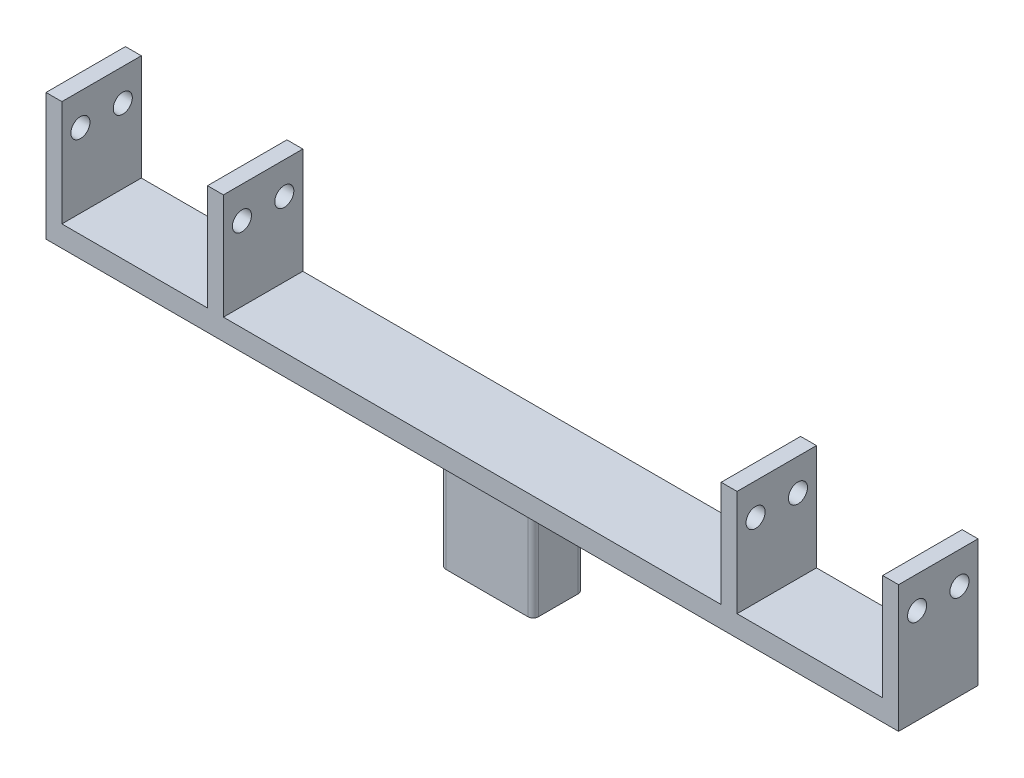
from build123d import *

# Parameters (mm, degrees)
SKETCH1_W               = 161
SKETCH1_H               = 15
BOSS_EXTRUDE1_DEPTH     = 4
SKETCH2_W               = 3
SKETCH2_H               = 15
BOSS_EXTRUDE2_DEPTH     = 20
SKETCH4_R               = 1.8
CUT_EXTRUDE2_DEPTH      = 1
CUT_EXTRUDE2_DEPTH_BACK = 162
BOSS_EXTRUDE3_DEPTH     = 19


with BuildPart() as part:
    # Sketch1 → Boss-Extrude1 (new body)
    with BuildSketch(Plane(origin=(0, 0, 0), x_dir=(1, 0, 0), z_dir=(0, 1, 0))):
        Rectangle(SKETCH1_W, SKETCH1_H)
    extrude(amount=BOSS_EXTRUDE1_DEPTH)

    # Sketch2 → Boss-Extrude2 (add)
    with BuildSketch(Plane(origin=(0, 4, 0), x_dir=(1, 0, 0), z_dir=(0, 1, 0))):
        with Locations((-48.5, 0)):
            Rectangle(SKETCH2_W, SKETCH2_H)
        with Locations((-79, 0)):
            Rectangle(SKETCH2_W, SKETCH2_H)
        with Locations((79, 0)):
            Rectangle(SKETCH2_W, SKETCH2_H)
        with Locations((48.5, 0)):
            Rectangle(SKETCH2_W, SKETCH2_H)
    extrude(amount=BOSS_EXTRUDE2_DEPTH)

    # Sketch4 → Cut-Extrude2 (cut, two sides)
    with BuildSketch(Plane.ZY.offset(80.5)) as cut_extrude2_sk:
        with Locations((4, 18)):
            Circle(SKETCH4_R)
        with Locations((-4, 18)):
            Circle(SKETCH4_R)
    extrude(amount=CUT_EXTRUDE2_DEPTH, mode=Mode.SUBTRACT)
    extrude(cut_extrude2_sk.sketch, amount=-CUT_EXTRUDE2_DEPTH_BACK, mode=Mode.SUBTRACT)

    # Sketch5 → Boss-Extrude3 (add)
    with BuildSketch(Plane.XZ):
        with BuildLine():
            Line((-7.75, -4.75), (7.75, -4.75))
            ThreePointArc((7.75, -4.75), (8.457106781, -4.457106781), (8.75, -3.75))
            Line((8.75, -3.75), (8.75, 3.75))
            ThreePointArc((8.75, 3.75), (8.457106781, 4.457106781), (7.75, 4.75))
            Line((7.75, 4.75), (-7.75, 4.75))
            ThreePointArc((-7.75, 4.75), (-8.457106781, 4.457106781), (-8.75, 3.75))
            Line((-8.75, 3.75), (-8.75, -3.75))
            ThreePointArc((-8.75, -3.75), (-8.457106781, -4.457106781), (-7.75, -4.75))
        make_face()
    extrude(amount=BOSS_EXTRUDE3_DEPTH)


solid = part.part
